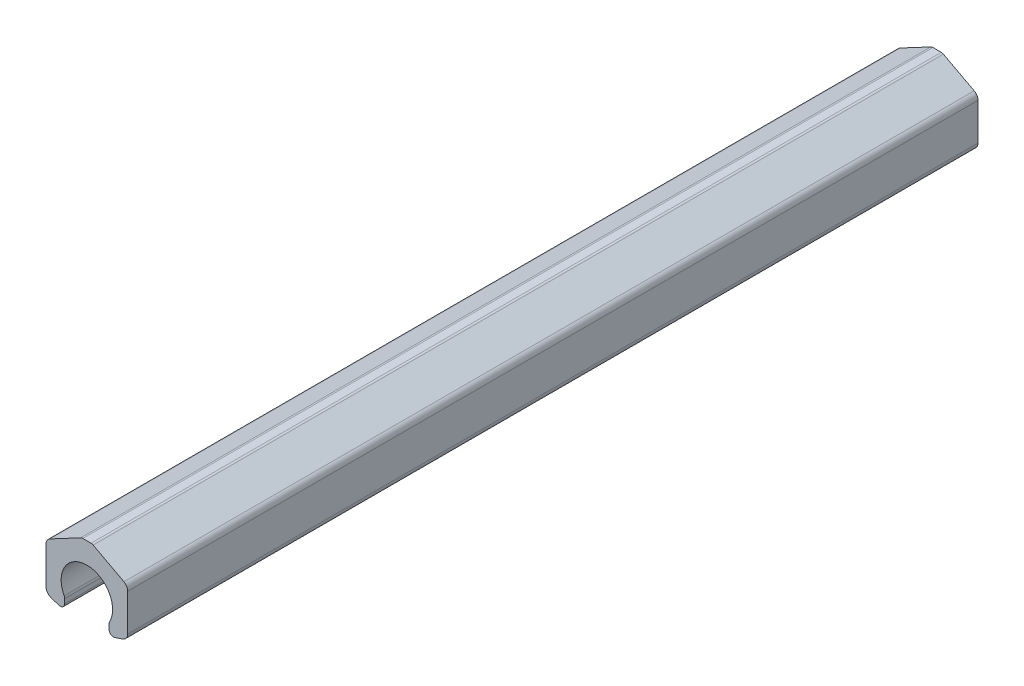
from build123d import *

# Parameters (mm, degrees)
EXTRUDE1_DEPTH = 609.6


with BuildPart() as part:
    # Sketch1 → Extrude1 (new body)
    with BuildSketch(Plane.XY):
        with BuildLine():
            Line((2.9718, 33.528), (-2.9718, 33.528))
            ThreePointArc((-2.9718, 33.528), (-3.739183777, 33.43386792), (-4.46106492, 33.157053316))
            Line((-4.46106492, 33.157053316), (-26.56126623, 21.419382585))
            ThreePointArc((-26.56126623, 21.419382585), (-28.56180679, 19.522269649), (-29.2989, 16.8656))
            Line((-29.2989, 16.8656), (-29.2989, -9.652))
            ThreePointArc((-29.2989, -9.652), (-28.394883916, -12.568389957), (-25.999830769, -14.462141759))
            ThreePointArc((-25.999830769, -14.462141759), (-22.985772925, -15.549597701), (-19.926426205, -16.502227094))
            ThreePointArc((-19.926426205, -16.502227094), (-17.139768103, -15.98665549), (-15.875, -13.450587845))
            Line((-15.875, -13.450587845), (-15.875, -10.240713335))
            ThreePointArc((-15.875, -10.240713335), (-15.971069561, -9.465592471), (-16.253464474, -8.737379023))
            ThreePointArc((-16.253464474, -8.737379023), (0, 18.4531), (16.253464474, -8.737379023))
            ThreePointArc((16.253464474, -8.737379023), (15.971069561, -9.465592471), (15.875, -10.240713335))
            Line((15.875, -10.240713335), (15.875, -13.450587845))
            ThreePointArc((15.875, -13.450587845), (17.139768103, -15.98665549), (19.926426205, -16.502227094))
            ThreePointArc((19.926426205, -16.502227094), (22.985772925, -15.549597701), (25.999830769, -14.462141759))
            ThreePointArc((25.999830769, -14.462141759), (28.394883916, -12.568389957), (29.2989, -9.652))
            Line((29.2989, -9.652), (29.2989, 16.8656))
            ThreePointArc((29.2989, 16.8656), (28.56180679, 19.522269649), (26.56126623, 21.419382585))
            Line((26.56126623, 21.419382585), (4.46106492, 33.157053316))
            ThreePointArc((4.46106492, 33.157053316), (3.739183777, 33.43386792), (2.9718, 33.528))
        make_face()
    extrude(amount=-EXTRUDE1_DEPTH)


solid = part.part
